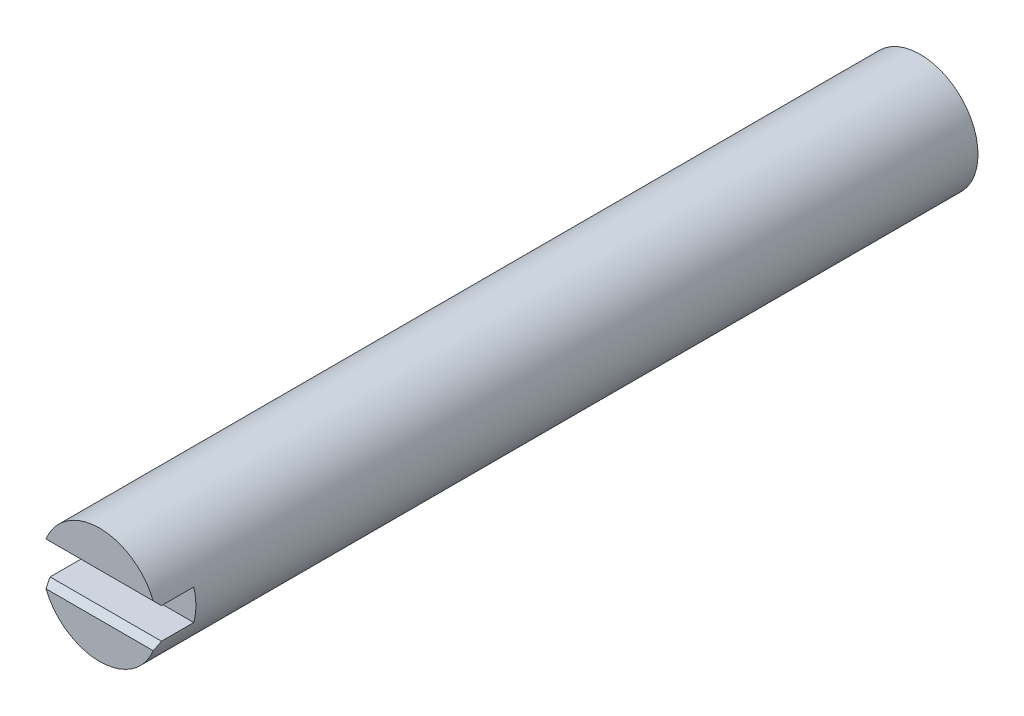
from build123d import *

# Parameters (mm, degrees)
SKETCH1_R           = 4.7625
BOSS_EXTRUDE1_DEPTH = 67.6402
SKETCH2_W           = 9.525
SKETCH2_H           = 2.54
CUT_EXTRUDE1_DEPTH  = 3.175
CHAMFER1_SIZE       = 0.508


with BuildPart() as part:
    # Sketch1 → Boss-Extrude1 (new body)
    with BuildSketch(Plane.XY):
        Circle(SKETCH1_R)
    extrude(amount=-BOSS_EXTRUDE1_DEPTH)

    # Sketch2 → Cut-Extrude1 (cut)
    with BuildSketch(Plane.XY):
        Rectangle(SKETCH2_W, SKETCH2_H)
    extrude(amount=-CUT_EXTRUDE1_DEPTH, mode=Mode.SUBTRACT)

    # Chamfer1
    chamfer1_edges = [part.edges().sort_by_distance(p)[0] for p in [
        (0, -1.27, 0),
        (0, 1.27, 0),
    ]]
    chamfer(chamfer1_edges, length=CHAMFER1_SIZE)


solid = part.part
